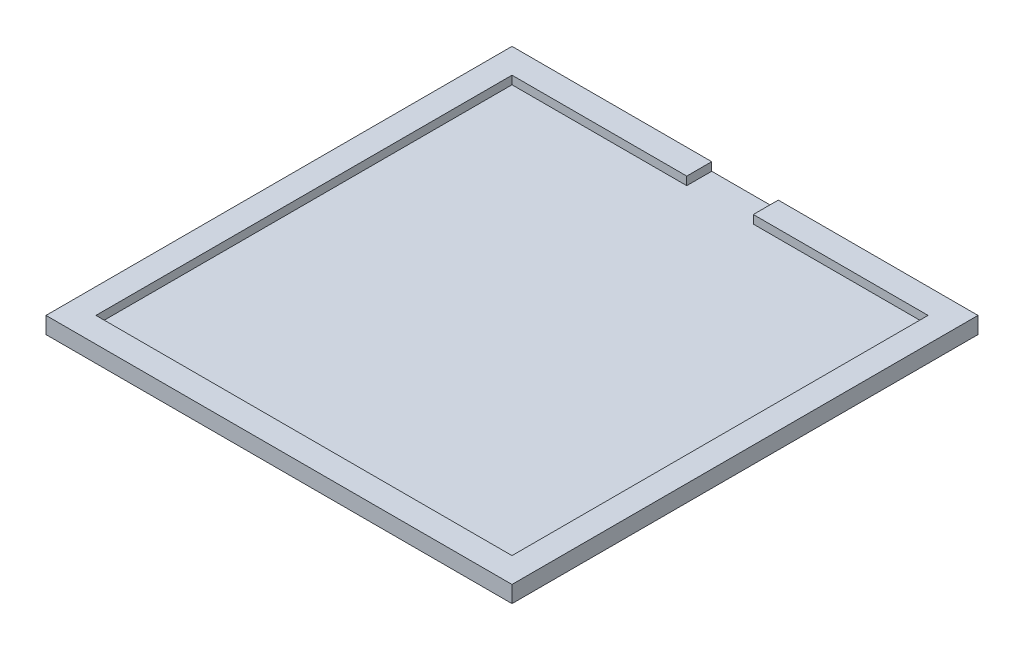
from build123d import *

# Parameters (mm, degrees)
SKETCH1_W           = 56
SKETCH1_H           = 56
BOSS_EXTRUDE1_DEPTH = 1
SKETCH1_3_W         = 56
SKETCH1_3_H         = 56
SKETCH1_3_W_2       = 50
SKETCH1_3_H_2       = 50
BOSS_EXTRUDE2_DEPTH = 2
SKETCH2_W           = 8
SKETCH2_H           = 19.436412374
CUT_EXTRUDE1_DEPTH  = 1


with BuildPart() as part:
    # Sketch1 → Boss-Extrude1 (new body)
    with BuildSketch(Plane(origin=(0, 0, 0), x_dir=(1, 0, 0), z_dir=(0, 1, 0))):
        Rectangle(SKETCH1_W, SKETCH1_H)
    extrude(amount=BOSS_EXTRUDE1_DEPTH)

    # Sketch1_3 → Boss-Extrude2 (add)
    with BuildSketch(Plane(origin=(0, 0, 0), x_dir=(1, 0, 0), z_dir=(0, 1, 0))):
        Rectangle(SKETCH1_3_W, SKETCH1_3_H)
        Rectangle(SKETCH1_3_W_2, SKETCH1_3_H_2, mode=Mode.SUBTRACT)
    extrude(amount=BOSS_EXTRUDE2_DEPTH)

    # Sketch2 → Cut-Extrude1 (cut)
    with BuildSketch(Plane(origin=(0, 2, 0), x_dir=(1, 0, 0), z_dir=(0, 1, 0))):
        with Locations((0, 31.957312715)):
            Rectangle(SKETCH2_W, SKETCH2_H)
    extrude(amount=-CUT_EXTRUDE1_DEPTH, mode=Mode.SUBTRACT)


solid = part.part
